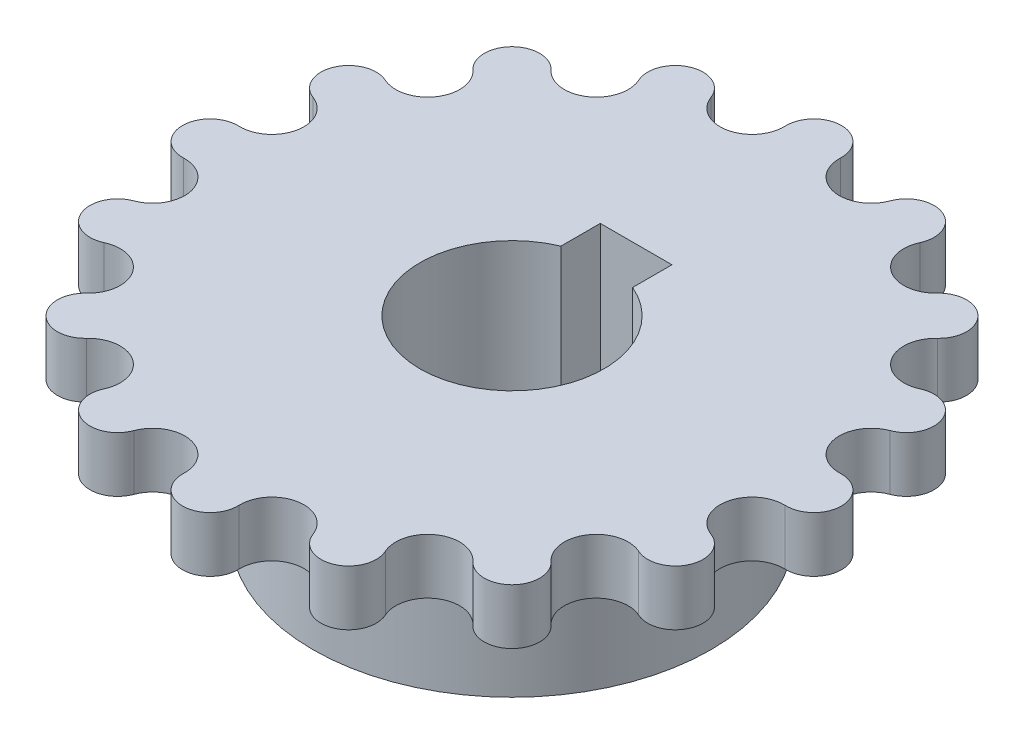
from build123d import *

# Parameters (mm, degrees)
SKETCH2_R           = 10.795
BOSS_EXTRUDE1_DEPTH = 10.287
SKETCH3_R           = 17.8689
BOSS_EXTRUDE2_DEPTH = 2.9972
CUT_EXTRUDE1_DEPTH  = 11.287
CUT_EXTRUDE2_DEPTH  = 11.287


with BuildPart() as part:
    # Sketch2 → Boss-Extrude1 (new body)
    with BuildSketch(Plane(origin=(0, 0, 0), x_dir=(1, 0, 0), z_dir=(0, 1, 0))):
        Circle(SKETCH2_R)
    extrude(amount=BOSS_EXTRUDE1_DEPTH)

    # Sketch3 → Boss-Extrude2 (add)
    with BuildSketch(Plane(origin=(0, 10.287, 0), x_dir=(1, 0, 0), z_dir=(0, 1, 0))):
        Circle(SKETCH3_R)
    extrude(amount=-BOSS_EXTRUDE2_DEPTH)

    # Sketch4 → Cut-Extrude1 (cut, through all)
    with BuildSketch(Plane(origin=(0, 10.287, 0), x_dir=(1, 0, 0), z_dir=(0, 1, 0))):
        with BuildLine():
            ThreePointArc((1.4e-08, 17.8689), (1.079645228, 17.410056336), (1.4986, 16.314315402))
            ThreePointArc((1.4986, 16.314315402), (3.196164746, 16.068205249), (4.858692347, 15.645951479))
            ThreePointArc((4.858692347, 15.645951479), (5.665077892, 16.497957009), (6.838131777, 16.508711064))
            ThreePointArc((6.838131777, 16.508711064), (3.486049352, 17.525554117), (1.4e-08, 17.8689))
        make_face()
        with BuildLine():
            ThreePointArc((4.858692347, 15.645951479), (3.196164746, 16.068205249), (1.4986, 16.314315402))
            ThreePointArc((1.4986, 16.314315402), (2.893978636, 14.549013087), (4.858692347, 15.645951479))
        make_face()
        with BuildLine():
            ThreePointArc((12.63522035, 12.635220375), (9.927428836, 14.857447422), (6.838131777, 16.508711064))
            ThreePointArc((6.838131777, 16.508711064), (7.660002201, 15.671632478), (7.627744082, 14.498972695))
            ThreePointArc((7.627744082, 14.498972695), (9.101907128, 13.621966658), (10.476292829, 12.595633274))
            ThreePointArc((10.476292829, 12.595633274), (11.547344433, 13.074193358), (12.63522035, 12.635220375))
        make_face()
        with BuildLine():
            ThreePointArc((10.476292829, 12.595633274), (9.101907128, 13.621966658), (7.627744082, 14.498972695))
            ThreePointArc((7.627744082, 14.498972695), (8.241353895, 12.334057732), (10.476292829, 12.595633274))
        make_face()
        with BuildLine():
            ThreePointArc((16.508710924, 6.838132115), (14.857447311, 9.927429003), (12.63522035, 12.635220375))
            ThreePointArc((12.63522035, 12.635220375), (13.074193359, 11.54734445), (12.595633274, 10.476292829))
            ThreePointArc((12.595633274, 10.476292829), (13.621966658, 9.101907128), (14.498972695, 7.627744082))
            ThreePointArc((14.498972695, 7.627744082), (15.671632308, 7.660002268), (16.508710924, 6.838132115))
        make_face()
        with BuildLine():
            ThreePointArc((14.498972695, 7.627744082), (13.621966658, 9.101907128), (12.595633274, 10.476292829))
            ThreePointArc((12.595633274, 10.476292829), (12.334057732, 8.241353895), (14.498972695, 7.627744082))
        make_face()
        with BuildLine():
            ThreePointArc((17.8689, 0), (17.525554083, 3.486049525), (16.508710924, 6.838132115))
            ThreePointArc((16.508710924, 6.838132115), (16.497957082, 5.665078059), (15.645951479, 4.858692347))
            ThreePointArc((15.645951479, 4.858692347), (16.068205249, 3.196164746), (16.314315402, 1.4986))
            ThreePointArc((16.314315402, 1.4986), (17.410056341, 1.079645223), (17.8689, 0))
        make_face()
        with BuildLine():
            ThreePointArc((16.314315402, 1.4986), (16.068205249, 3.196164746), (15.645951479, 4.858692347))
            ThreePointArc((15.645951479, 4.858692347), (14.549013087, 2.893978636), (16.314315402, 1.4986))
        make_face()
        with BuildLine():
            ThreePointArc((16.508710924, -6.838132115), (17.525554083, -3.486049525), (17.8689, 0))
            ThreePointArc((17.8689, 0), (17.410056341, -1.079645223), (16.314315402, -1.4986))
            ThreePointArc((16.314315402, -1.4986), (16.068205249, -3.196164746), (15.645951479, -4.858692347))
            ThreePointArc((15.645951479, -4.858692347), (16.497957082, -5.665078059), (16.508710924, -6.838132115))
        make_face()
        with BuildLine():
            ThreePointArc((15.645951479, -4.858692347), (16.068205249, -3.196164746), (16.314315402, -1.4986))
            ThreePointArc((16.314315402, -1.4986), (14.549013087, -2.893978636), (15.645951479, -4.858692347))
        make_face()
        with BuildLine():
            ThreePointArc((12.635220358, -12.635220367), (14.857447314, -9.927428998), (16.508710924, -6.838132115))
            ThreePointArc((16.508710924, -6.838132115), (15.671632308, -7.660002268), (14.498972695, -7.627744082))
            ThreePointArc((14.498972695, -7.627744082), (13.621966658, -9.101907128), (12.595633274, -10.476292829))
            ThreePointArc((12.595633274, -10.476292829), (13.074193359, -11.547344445), (12.635220358, -12.635220367))
        make_face()
        with BuildLine():
            ThreePointArc((12.595633274, -10.476292829), (13.621966658, -9.101907128), (14.498972695, -7.627744082))
            ThreePointArc((14.498972695, -7.627744082), (12.334057732, -8.241353895), (12.595633274, -10.476292829))
        make_face()
        with BuildLine():
            ThreePointArc((6.838132083, -16.508710938), (9.927428978, -14.857447327), (12.635220358, -12.635220367))
            ThreePointArc((12.635220358, -12.635220367), (11.547344438, -13.074193358), (10.476292829, -12.595633274))
            ThreePointArc((10.476292829, -12.595633274), (9.101907128, -13.621966658), (7.627744082, -14.498972695))
            ThreePointArc((7.627744082, -14.498972695), (7.660002262, -15.671632324), (6.838132083, -16.508710938))
        make_face()
        with BuildLine():
            ThreePointArc((7.627744082, -14.498972695), (9.101907128, -13.621966658), (10.476292829, -12.595633274))
            ThreePointArc((10.476292829, -12.595633274), (8.241353895, -12.334057732), (7.627744082, -14.498972695))
        make_face()
        with BuildLine():
            ThreePointArc((0, -17.8689), (3.486049507, -17.525554087), (6.838132083, -16.508710938))
            ThreePointArc((6.838132083, -16.508710938), (5.665078043, -16.497957075), (4.858692347, -15.645951479))
            ThreePointArc((4.858692347, -15.645951479), (3.196164746, -16.068205249), (1.4986, -16.314315402))
            ThreePointArc((1.4986, -16.314315402), (1.079645223, -17.410056341), (0, -17.8689))
        make_face()
        with BuildLine():
            ThreePointArc((1.4986, -16.314315402), (3.196164746, -16.068205249), (4.858692347, -15.645951479))
            ThreePointArc((4.858692347, -15.645951479), (2.893978636, -14.549013087), (1.4986, -16.314315402))
        make_face()
        with BuildLine():
            ThreePointArc((-4.858692347, -15.645951479), (-5.665078063, -16.497957083), (-6.838132123, -16.508710921))
            ThreePointArc((-6.838132123, -16.508710921), (-3.486049529, -17.525554082), (0, -17.8689))
            ThreePointArc((0, -17.8689), (-1.079645223, -17.410056341), (-1.4986, -16.314315402))
            ThreePointArc((-1.4986, -16.314315402), (-3.196164746, -16.068205249), (-4.858692347, -15.645951479))
        make_face()
        with BuildLine():
            ThreePointArc((-1.4986, -16.314315402), (-2.893978636, -14.549013087), (-4.858692347, -15.645951479))
            ThreePointArc((-4.858692347, -15.645951479), (-3.196164746, -16.068205249), (-1.4986, -16.314315402))
        make_face()
        with BuildLine():
            ThreePointArc((-7.627744082, -14.498972695), (-8.241353895, -12.334057732), (-10.476292829, -12.595633274))
            ThreePointArc((-10.476292829, -12.595633274), (-9.101907128, -13.621966658), (-7.627744082, -14.498972695))
        make_face()
        with BuildLine():
            ThreePointArc((-14.498972695, -7.627744082), (-15.671632446, -7.660002214), (-16.508711038, -6.838131842))
            ThreePointArc((-16.508711038, -6.838131842), (-14.857447398, -9.927428873), (-12.635220362, -12.635220362))
            ThreePointArc((-12.635220362, -12.635220362), (-13.074193358, -11.547344441), (-12.595633274, -10.476292829))
            ThreePointArc((-12.595633274, -10.476292829), (-13.621966658, -9.101907128), (-14.498972695, -7.627744082))
        make_face()
        with BuildLine():
            ThreePointArc((-12.595633274, -10.476292829), (-12.334057732, -8.241353895), (-14.498972695, -7.627744082))
            ThreePointArc((-14.498972695, -7.627744082), (-13.621966658, -9.101907128), (-12.595633274, -10.476292829))
        make_face()
        with BuildLine():
            ThreePointArc((-16.314315402, -1.4986), (-17.410056347, -1.079645218), (-17.8689, 1.4e-08))
            ThreePointArc((-17.8689, 1.4e-08), (-17.525554113, -3.486049372), (-16.508711038, -6.838131842))
            ThreePointArc((-16.508711038, -6.838131842), (-16.497957023, -5.665077924), (-15.645951479, -4.858692347))
            ThreePointArc((-15.645951479, -4.858692347), (-16.068205249, -3.196164746), (-16.314315402, -1.4986))
        make_face()
        with BuildLine():
            ThreePointArc((-15.645951479, -4.858692347), (-14.549013087, -2.893978636), (-16.314315402, -1.4986))
            ThreePointArc((-16.314315402, -1.4986), (-16.068205249, -3.196164746), (-15.645951479, -4.858692347))
        make_face()
        with BuildLine():
            ThreePointArc((-15.645951479, 4.858692347), (-16.497957093, 5.665078085), (-16.508710903, 6.838132168))
            ThreePointArc((-16.508710903, 6.838132168), (-17.525554076, 3.486049559), (-17.8689, 1.4e-08))
            ThreePointArc((-17.8689, 1.4e-08), (-17.410056336, 1.079645228), (-16.314315402, 1.4986))
            ThreePointArc((-16.314315402, 1.4986), (-16.068205249, 3.196164746), (-15.645951479, 4.858692347))
        make_face()
        with BuildLine():
            ThreePointArc((-16.314315402, 1.4986), (-14.549013087, 2.893978636), (-15.645951479, 4.858692347))
            ThreePointArc((-15.645951479, 4.858692347), (-16.068205249, 3.196164746), (-16.314315402, 1.4986))
        make_face()
        with BuildLine():
            ThreePointArc((-12.595633274, 10.476292829), (-13.074193358, 11.547344436), (-12.63522037, 12.635220355))
            ThreePointArc((-12.63522037, 12.635220355), (-14.857447303, 9.927429015), (-16.508710903, 6.838132168))
            ThreePointArc((-16.508710903, 6.838132168), (-15.671632282, 7.660002279), (-14.498972695, 7.627744082))
            ThreePointArc((-14.498972695, 7.627744082), (-13.621966658, 9.101907128), (-12.595633274, 10.476292829))
        make_face()
        with BuildLine():
            ThreePointArc((-14.498972695, 7.627744082), (-12.334057732, 8.241353895), (-12.595633274, 10.476292829))
            ThreePointArc((-12.595633274, 10.476292829), (-13.621966658, 9.101907128), (-14.498972695, 7.627744082))
        make_face()
        with BuildLine():
            ThreePointArc((-7.627744082, 14.498972695), (-7.660002268, 15.671632308), (-6.838132115, 16.508710924))
            ThreePointArc((-6.838132115, 16.508710924), (-9.927429, 14.857447313), (-12.63522037, 12.635220355))
            ThreePointArc((-12.63522037, 12.635220355), (-11.547344447, 13.074193359), (-10.476292829, 12.595633274))
            ThreePointArc((-10.476292829, 12.595633274), (-9.101907128, 13.621966658), (-7.627744082, 14.498972695))
        make_face()
        with BuildLine():
            ThreePointArc((-10.476292829, 12.595633274), (-8.241353895, 12.334057732), (-7.627744082, 14.498972695))
            ThreePointArc((-7.627744082, 14.498972695), (-9.101907128, 13.621966658), (-10.476292829, 12.595633274))
        make_face()
        with BuildLine():
            ThreePointArc((-4.858692347, 15.645951479), (-2.893978636, 14.549013087), (-1.4986, 16.314315402))
            ThreePointArc((-1.4986, 16.314315402), (-3.196164746, 16.068205249), (-4.858692347, 15.645951479))
        make_face()
        with BuildLine():
            ThreePointArc((-1.4986, 16.314315402), (-1.079645218, 17.410056347), (1.4e-08, 17.8689))
            ThreePointArc((1.4e-08, 17.8689), (-3.486049518, 17.525554085), (-6.838132115, 16.508710924))
            ThreePointArc((-6.838132115, 16.508710924), (-5.665078059, 16.497957082), (-4.858692347, 15.645951479))
            ThreePointArc((-4.858692347, 15.645951479), (-3.196164746, 16.068205249), (-1.4986, 16.314315402))
        make_face()
        with BuildLine():
            ThreePointArc((-10.476292829, -12.595633274), (-11.547344441, -13.074193358), (-12.635220362, -12.635220362))
            ThreePointArc((-12.635220362, -12.635220362), (-9.927428999, -14.857447314), (-6.838132123, -16.508710921))
            ThreePointArc((-6.838132123, -16.508710921), (-7.66000227, -15.671632304), (-7.627744082, -14.498972695))
            ThreePointArc((-7.627744082, -14.498972695), (-9.101907128, -13.621966658), (-10.476292829, -12.595633274))
        make_face()
    extrude(amount=-CUT_EXTRUDE1_DEPTH, mode=Mode.SUBTRACT)

    # Sketch5 → Cut-Extrude2 (cut, through all)
    with BuildSketch(Plane(origin=(0, 10.287, 0), x_dir=(1, 0, 0), z_dir=(0, 1, 0))):
        with BuildLine():
            Line((-1.9431, 4.597329834), (-1.9431, 6.731))
            Line((-1.9431, 6.731), (1.9431, 6.731))
            Line((1.9431, 6.731), (1.9431, 4.597329834))
            ThreePointArc((1.9431, 4.597329834), (0, -4.9911), (-1.9431, 4.597329834))
        make_face()
    extrude(amount=-CUT_EXTRUDE2_DEPTH, mode=Mode.SUBTRACT)


solid = part.part
